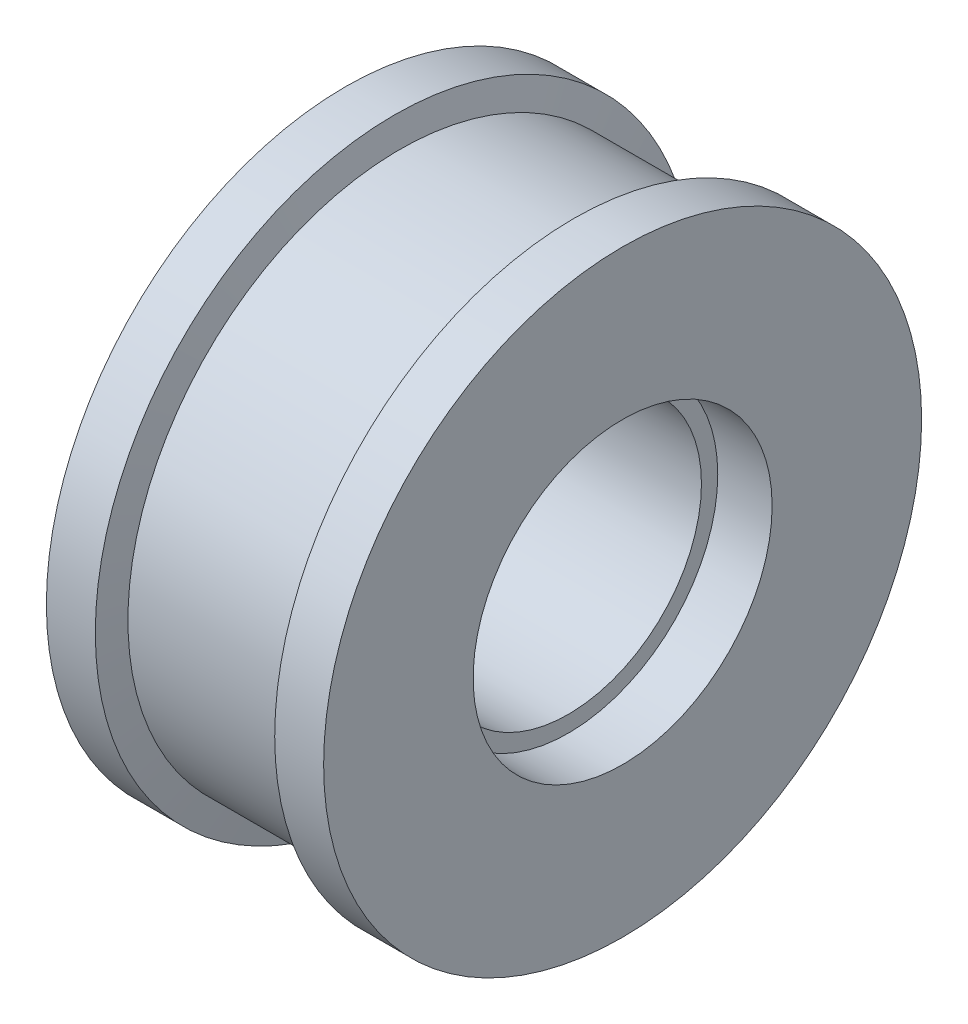
from build123d import *


with BuildPart() as part:
    # 草图1 → 旋转1 (revolve)
    with BuildSketch(Plane(origin=(0, 0, 6531.222724472), x_dir=(-1, 0, 0), z_dir=(0, 1, 0))):
        Polygon((-9, -6476.222724472), (-10, -6481.222724472), (-41, -6481.222724472), (-42, -6476.222724472), (-51, -6476.222724472), (-51, -6503.722724472), (-41, -6503.722724472), (-41, -6506.722724472), (-10, -6506.722724472), (-10, -6503.722724472), (0, -6503.722724472), (0, -6476.222724472), align=None)
    revolve(axis=Axis((51, 0, 0), (-1, 0, 0)))


solid = part.part
